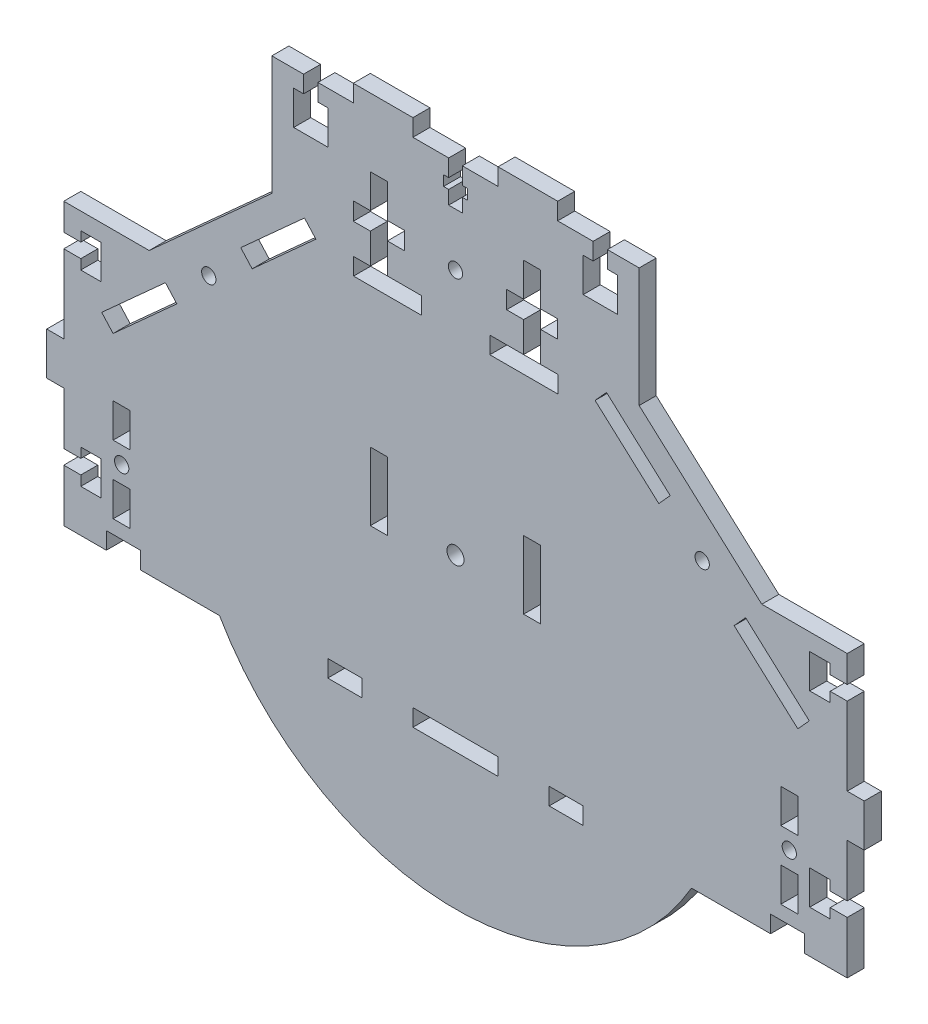
from build123d import *

# Parameters (mm, degrees)
SKETCH1_W            = 240
SKETCH1_H            = 210
BOSS_EXTRUDE1_DEPTH  = 5
SKETCH2_W            = 240
SKETCH2_H            = 65
CUT_EXTRUDE1_DEPTH   = 5
SKETCH4_W            = 100
SKETCH4_H            = 5
BOSS_EXTRUDE2_DEPTH  = 10
SKETCH5_W            = 5
SKETCH5_H            = 35
SKETCH5_W_2          = 60
SKETCH5_H_2          = 5
CUT_EXTRUDE3_DEPTH   = 10
SKETCH6_W            = 5
SKETCH6_H            = 10
BOSS_EXTRUDE3_DEPTH  = 15
BOSS_EXTRUDE9_DEPTH  = 5
SKETCH13_W           = 5
SKETCH13_H           = 35
CUT_EXTRUDE4_DEPTH   = 10
SKETCH15_R           = 2.1
SKETCH15_W           = 15
SKETCH15_H           = 5.2
CUT_EXTRUDE8_DEPTH   = 10
SKETCH16_R           = 2.1
CUT_EXTRUDE9_DEPTH   = 10
SKETCH17_W           = 25
SKETCH17_H           = 5
SKETCH17_W_2         = 10
CUT_EXTRUDE10_DEPTH  = 10
SKETCH19_W           = 25
SKETCH19_H           = 5
SKETCH19_W_2         = 4
SKETCH19_H_2         = 3
SKETCH19_H_3         = 4
SKETCH19_W_3         = 1.5
CUT_EXTRUDE12_DEPTH  = 10
CUT_EXTRUDE13_DEPTH  = 10
SKETCH21_W           = 5
SKETCH21_H           = 25
CUT_EXTRUDE14_DEPTH  = 5
SKETCH22_W           = 5
SKETCH22_H           = 4.2
CUT_EXTRUDE15_DEPTH  = 5
SKETCH23_W           = 5
SKETCH23_H           = 25
CUT_EXTRUDE16_DEPTH  = 10
SKETCH24_W           = 5
SKETCH24_H           = 5
BOSS_EXTRUDE10_DEPTH = 5
SKETCH26_W           = 5
SKETCH26_H           = 5
BOSS_EXTRUDE12_DEPTH = 5
SKETCH27_R           = 2.5
CUT_EXTRUDE17_DEPTH  = 5
SKETCH28_W           = 5
SKETCH28_H           = 5
CUT_EXTRUDE18_DEPTH  = 10
SKETCH29_W           = 5
SKETCH29_H           = 5
CUT_EXTRUDE19_DEPTH  = 10
SKETCH30_W           = 10
SKETCH30_H           = 8.2
SKETCH30_W_2         = 4.2
SKETCH30_H_2         = 5
CUT_EXTRUDE20_DEPTH  = 10
SKETCH31_W           = 10
SKETCH31_H           = 5
CUT_EXTRUDE21_DEPTH  = 5
SKETCH32_W           = 20
SKETCH32_H           = 5
CUT_EXTRUDE22_DEPTH  = 5
SKETCH33_W           = 10
SKETCH33_H           = 1.8
CUT_EXTRUDE23_DEPTH  = 5
SKETCH34_R           = 2.1
SKETCH34_W           = 5
SKETCH34_H           = 10
CUT_EXTRUDE24_DEPTH  = 5


with BuildPart() as part:
    # Sketch1 → Boss-Extrude1 (new body)
    with BuildSketch(Plane.XY):
        with Locations((-120, 105)):
            Rectangle(SKETCH1_W, SKETCH1_H)
    extrude(amount=BOSS_EXTRUDE1_DEPTH)

    # Sketch2 → Cut-Extrude1 (cut)
    with BuildSketch(Plane.XY.offset(5)):
        with Locations((-120, 32.5)):
            Rectangle(SKETCH2_W, SKETCH2_H)
    extrude(amount=-CUT_EXTRUDE1_DEPTH, mode=Mode.SUBTRACT)

    # Sketch4 → Boss-Extrude2 (add)
    with BuildSketch(Plane.XZ.offset(-65)):
        with Locations((-170, 2.5)):
            Rectangle(SKETCH4_W, SKETCH4_H)
        with Locations((-70, 2.5)):
            Rectangle(SKETCH4_W, SKETCH4_H)
    extrude(amount=BOSS_EXTRUDE2_DEPTH)

    # Sketch5 → Cut-Extrude3 (cut)
    with BuildSketch(Plane.XY.offset(5)):
        with Locations((-237.5, 192.5)):
            Rectangle(SKETCH5_W, SKETCH5_H)
        with Locations((-2.5, 192.5)):
            Rectangle(SKETCH5_W, SKETCH5_H)
        with Locations((-50, 207.5)):
            Rectangle(SKETCH5_W_2, SKETCH5_H_2)
        with Locations((-190, 207.5)):
            Rectangle(SKETCH5_W_2, SKETCH5_H_2)
    extrude(amount=-CUT_EXTRUDE3_DEPTH, mode=Mode.SUBTRACT)

    # Sketch6 → Boss-Extrude3 (add)
    with BuildSketch(Plane.ZY.offset(220)):
        with Locations((2.5, 60)):
            Rectangle(SKETCH6_W, SKETCH6_H)
    boss_extrude3 = extrude(amount=BOSS_EXTRUDE3_DEPTH)

    # Mirror1: Boss-Extrude3 across plane
    add(boss_extrude3.mirror(Plane.ZY.offset(120)))

    # Sketch12 → Boss-Extrude9 (add)
    with BuildSketch(Plane.XY.offset(5)):
        with BuildLine():
            Line((-189.282032303, 55), (-50.717967697, 55))
            ThreePointArc((-50.717967697, 55), (-120, 15), (-189.282032303, 55))
        make_face()
    extrude(amount=-BOSS_EXTRUDE9_DEPTH)

    # Sketch13 → Cut-Extrude4 (cut)
    with BuildSketch(Plane.XY.offset(5)):
        with Locations((-237.5, 120)):
            Rectangle(SKETCH13_W, SKETCH13_H)
        with Locations((-2.5, 120)):
            Rectangle(SKETCH13_W, SKETCH13_H)
    extrude(amount=-CUT_EXTRUDE4_DEPTH, mode=Mode.SUBTRACT)

    # Sketch15 → Cut-Extrude8 (cut)
    with BuildSketch(Plane.XY):
        with Locations((-120, 177.5)):
            Circle(SKETCH15_R)
        with Locations((-142.5, 177.5)):
            Rectangle(SKETCH15_W, SKETCH15_H)
        with Locations((-97.5, 177.5)):
            Rectangle(SKETCH15_W, SKETCH15_H)
    extrude(amount=CUT_EXTRUDE8_DEPTH, mode=Mode.SUBTRACT)

    # Sketch16 → Cut-Extrude9 (cut)
    with BuildSketch(Plane.XY.offset(5)):
        Polygon((-160.98556701, 164.847268071), (-179.690721649, 147.960670133), (-183.041237113, 151.672010339), (-164.336082474, 168.558608278), align=None)
        Polygon((-201.810309278, 127.991597968), (-220.515463918, 111.10500003), (-223.865979381, 114.816340236), (-205.160824742, 131.702938175), align=None)
        with Locations((-192.425773196, 139.831804154)):
            Circle(SKETCH16_R)
        Polygon((-75.663917526, 168.558608278), (-56.958762887, 151.672010339), (-60.309278351, 147.960670133), (-79.01443299, 164.847268071), align=None)
        with Locations((-47.574226804, 139.831804154)):
            Circle(SKETCH16_R)
        Polygon((-34.839175258, 131.702938175), (-16.134020619, 114.816340236), (-19.484536082, 111.10500003), (-38.189690722, 127.991597968), align=None)
    extrude(amount=-CUT_EXTRUDE9_DEPTH, mode=Mode.SUBTRACT)

    # Sketch17 → Cut-Extrude10 (cut)
    with BuildSketch(Plane(origin=(0, 0, 0), x_dir=(-1, 0, 0), z_dir=(0, 0, -1))):
        with Locations((120, 57.5)):
            Rectangle(SKETCH17_W, SKETCH17_H)
        with Locations((152.5, 57.5)):
            Rectangle(SKETCH17_W_2, SKETCH17_H)
        with Locations((87.5, 57.5)):
            Rectangle(SKETCH17_W_2, SKETCH17_H)
    extrude(amount=-CUT_EXTRUDE10_DEPTH, mode=Mode.SUBTRACT)

    # Sketch19 → Cut-Extrude12 (cut)
    with BuildSketch(Plane(origin=(0, 0, 0), x_dir=(-1, 0, 0), z_dir=(0, 0, -1))):
        with Locations((120, 207.5)):
            Rectangle(SKETCH19_W, SKETCH19_H)
        with Locations((120, 202.5)):
            Rectangle(SKETCH19_W_2, SKETCH19_H)
        with Locations((120, 198.5)):
            Rectangle(SKETCH19_W_2, SKETCH19_H_2)
        with Locations((120, 195)):
            Rectangle(SKETCH19_W_2, SKETCH19_H_3)
        with Locations((122.75, 198.5)):
            Rectangle(SKETCH19_W_3, SKETCH19_H_2)
        with Locations((117.25, 198.5)):
            Rectangle(SKETCH19_W_3, SKETCH19_H_2)
    extrude(amount=-CUT_EXTRUDE12_DEPTH, mode=Mode.SUBTRACT)

    # Sketch20 → Cut-Extrude13 (cut)
    with BuildSketch(Plane.XY.offset(5)):
        Polygon((-273.079166664, 137.5), (-209.931771643, 137.5), (-173.918106282, 170.012336785), (-173.918106282, 219.696537232), (-273.079166664, 219.696537232), align=None)
        Polygon((33.079166664, 137.5), (33.079166664, 219.696537232), (-66.081893718, 219.696537232), (-66.081893718, 170.012336785), (-30.068228357, 137.5), align=None)
    extrude(amount=-CUT_EXTRUDE13_DEPTH, mode=Mode.SUBTRACT)

    # Sketch21 → Cut-Extrude14 (cut)
    with BuildSketch(Plane(origin=(0, 0, 0), x_dir=(0, 0, -1), z_dir=(1, 0, 0))):
        with Locations((-2.5, 77.5)):
            Rectangle(SKETCH21_W, SKETCH21_H)
    cut_extrude14 = extrude(amount=-CUT_EXTRUDE14_DEPTH, mode=Mode.SUBTRACT)

    # Mirror2: Cut-Extrude14 across plane
    add(cut_extrude14.mirror(Plane.ZY.offset(120)), mode=Mode.SUBTRACT)

    # Sketch22 → Cut-Extrude15 (cut)
    with BuildSketch(Plane.XY.offset(5)):
        with Locations((-7.5, 72.5)):
            Rectangle(SKETCH22_W, SKETCH22_H)
        with Locations((-7.5, 127.5)):
            Rectangle(SKETCH22_W, SKETCH22_H)
        Polygon((-10, 67.5), (-10, 70.4), (-10, 74.6), (-10, 77.5), (-16, 77.5), (-16, 67.5), align=None)
        Polygon((-10, 125.4), (-10, 129.6), (-10, 132.5), (-16, 132.5), (-16, 122.5), (-10, 122.5), align=None)
    cut_extrude15 = extrude(amount=-CUT_EXTRUDE15_DEPTH, mode=Mode.SUBTRACT)

    # Mirror3: Cut-Extrude15 across plane
    add(cut_extrude15.mirror(Plane(origin=(-120, 0, 0), x_dir=(0, 0, 1), z_dir=(1, 0, 0))), mode=Mode.SUBTRACT)

    # Sketch23 → Cut-Extrude16 (cut)
    with BuildSketch(Plane(origin=(0, 0, 0), x_dir=(-1, 0, 0), z_dir=(0, 0, -1))):
        with Locations((142.5, 112.5)):
            Rectangle(SKETCH23_W, SKETCH23_H)
        with Locations((97.5, 112.5)):
            Rectangle(SKETCH23_W, SKETCH23_H)
        with Locations((142.5, 177.5)):
            Rectangle(SKETCH23_W, SKETCH23_H)
        with Locations((97.5, 177.5)):
            Rectangle(SKETCH23_W, SKETCH23_H)
    extrude(amount=-CUT_EXTRUDE16_DEPTH, mode=Mode.SUBTRACT)

    # Sketch24 → Boss-Extrude10 (add)
    with BuildSketch(Plane.XY.offset(5)):
        with Locations((-97.5, 122.5)):
            Rectangle(SKETCH24_W, SKETCH24_H)
    extrude(amount=-BOSS_EXTRUDE10_DEPTH)

    # Sketch26 → Boss-Extrude12 (add)
    with BuildSketch(Plane.XY.offset(5)):
        with Locations((-142.5, 122.5)):
            Rectangle(SKETCH26_W, SKETCH26_H)
    extrude(amount=-BOSS_EXTRUDE12_DEPTH)

    # Sketch27 → Cut-Extrude17 (cut)
    with BuildSketch(Plane.XY.offset(5)):
        with Locations((-120, 105)):
            Circle(SKETCH27_R)
    extrude(amount=-CUT_EXTRUDE17_DEPTH, mode=Mode.SUBTRACT)

    # Sketch28 → Cut-Extrude18 (cut)
    with BuildSketch(Plane.ZY.offset(160)):
        with Locations((2.5, 207.5)):
            Rectangle(SKETCH28_W, SKETCH28_H)
    extrude(amount=-CUT_EXTRUDE18_DEPTH, mode=Mode.SUBTRACT)

    # Sketch29 → Cut-Extrude19 (cut)
    with BuildSketch(Plane(origin=(-80, 0, 0), x_dir=(0, 0, -1), z_dir=(1, 0, 0))):
        with Locations((-2.5, 207.5)):
            Rectangle(SKETCH29_W, SKETCH29_H)
    extrude(amount=-CUT_EXTRUDE19_DEPTH, mode=Mode.SUBTRACT)

    # Sketch30 → Cut-Extrude20 (cut)
    with BuildSketch(Plane.XY.offset(5)):
        with Locations((-77.5, 195.9)):
            Rectangle(SKETCH30_W, SKETCH30_H)
        with Locations((-77.5, 202.5)):
            Rectangle(SKETCH30_W_2, SKETCH30_H_2)
        Polygon((-157.5, 200), (-160.4, 200), (-164.6, 200), (-167.5, 200), (-167.5, 191.8), (-157.5, 191.8), align=None)
        with Locations((-162.5, 202.5)):
            Rectangle(SKETCH30_W_2, SKETCH30_H_2)
    extrude(amount=-CUT_EXTRUDE20_DEPTH, mode=Mode.SUBTRACT)

    # Sketch31 → Cut-Extrude21 (cut)
    with BuildSketch(Plane.XZ.offset(-55)):
        with Locations((-217.5, 2.5)):
            Rectangle(SKETCH31_W, SKETCH31_H)
        with Locations((-22.5, 2.5)):
            Rectangle(SKETCH31_W, SKETCH31_H)
    extrude(amount=-CUT_EXTRUDE21_DEPTH, mode=Mode.SUBTRACT)

    # Sketch32 → Cut-Extrude22 (cut)
    with BuildSketch(Plane.XY.offset(5)):
        with Locations((-139.918106282, 163.5)):
            Rectangle(SKETCH32_W, SKETCH32_H)
        with Locations((-99.918106282, 163.5)):
            Rectangle(SKETCH32_W, SKETCH32_H)
    extrude(amount=-CUT_EXTRUDE22_DEPTH, mode=Mode.SUBTRACT)

    # Sketch33 → Cut-Extrude23 (cut)
    with BuildSketch(Plane.XY.offset(5)):
        with Locations((-162.5, 190.9)):
            Rectangle(SKETCH33_W, SKETCH33_H)
        with Locations((-77.5, 190.9)):
            Rectangle(SKETCH33_W, SKETCH33_H)
    extrude(amount=-CUT_EXTRUDE23_DEPTH, mode=Mode.SUBTRACT)

    # Sketch34 → Cut-Extrude24 (cut)
    with BuildSketch(Plane.XY.offset(5)):
        with Locations((-218, 79)):
            Circle(SKETCH34_R)
        with Locations((-22, 79)):
            Circle(SKETCH34_R)
        with Locations((-218, 69)):
            Rectangle(SKETCH34_W, SKETCH34_H)
        with Locations((-218, 89)):
            Rectangle(SKETCH34_W, SKETCH34_H)
        with Locations((-22, 89)):
            Rectangle(SKETCH34_W, SKETCH34_H)
        with Locations((-22, 69)):
            Rectangle(SKETCH34_W, SKETCH34_H)
    extrude(amount=-CUT_EXTRUDE24_DEPTH, mode=Mode.SUBTRACT)


solid = part.part
